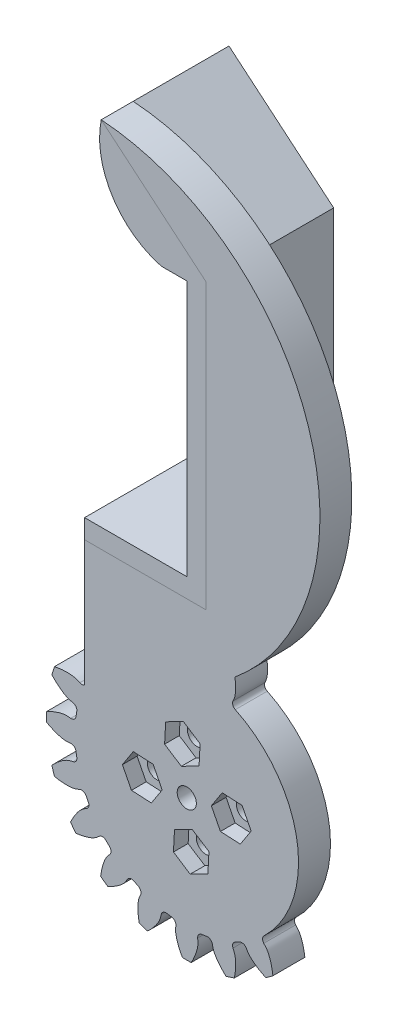
from build123d import *

# Parameters (mm, degrees)
SKETCH_1_R           = 22
LASHENA_DEPTH        = 5
CUT_EXTRUDEA_DEPTH   = 50
WWW_KYTOOL_CN_COUNT  = 20
EXTRUDE_2_DEPTH      = 15
EXTRUDE_2_DEPTH_BACK = 5
EXTRUDE_3_DEPTH      = 5
SKETCH_5_R           = 1.5
CUT_EXTRUDE_2_DEPTH  = 5
CUT_EXTRUDE_4_DEPTH  = 2.3


with BuildPart() as part:
    # 草图1 → LaShenA (new body)
    with BuildSketch(Plane.XY):
        Circle(SKETCH_1_R)
    extrude(amount=LASHENA_DEPTH)

    # SketchA → Cut-ExtrudeA (cut)
    with BuildSketch(Plane.XY.offset(5)):
        with BuildLine():
            ThreePointArc((-2.356349611, 17.340634836), (-2.737603138, 17.28454596), (-3.117529205, 17.220075832))
            ThreePointArc((-3.117529205, 17.220075832), (-3.673572605, 17.334949471), (-3.994833481, 17.803107206))
            add(Edge.make_bspline(
                [(-3.994833481, 17.803107206), (-4.034691495, 17.98253134), (-4.076537521, 18.219177773), (-4.157204778, 18.47396401), (-4.199055268, 18.580395528), (-4.234392911, 18.664311698), (-4.277870663, 18.759955155), (-4.330045748, 18.866984119), (-4.391601943, 18.984969425), (-4.463160419, 19.113474646), (-4.545339737, 19.2520309), (-4.638735544, 19.400145657), (-4.743925671, 19.557300848), (-4.861467358, 19.722954334), (-4.991896938, 19.896540395), (-5.135728792, 20.077470549), (-5.293454567, 20.265134311), (-5.465542346, 20.458900012), (-5.65243587, 20.658115632), (-5.854553762, 20.862109666), (-6.07228887, 21.070192005), (-6.3060073, 21.281654905), (-6.646489341, 21.573220913), (-6.916345556, 21.785433413), (-7.103559199, 21.924886291)],
                knots=[0.125068197, 0.125068197, 0.125068197, 0.125068197, 0.215847125, 0.244833276, 0.257593391, 0.272673526, 0.290073681, 0.309793857, 0.331834054, 0.356194271, 0.382874509, 0.411874767, 0.443195046, 0.476835345, 0.512795666, 0.551076006, 0.591676368, 0.634596749, 0.679837152, 0.727397575, 0.777278019, 0.829478483, 0.883998968, 1, 1, 1, 1], degree=3))
            ThreePointArc((-7.103559199, 21.924886291), (-3.605334877, 22.763188542), (-0.019276198, 23.046926489))
            add(Edge.make_bspline(
                [(-1.702150265, 18.166232554), (-1.719688148, 18.349191849), (-1.753017983, 18.587187115), (-1.755032138, 18.854430779), (-1.748119105, 18.96858568), (-1.740442532, 19.059314632), (-1.728648187, 19.16371233), (-1.712100501, 19.281625912), (-1.690016545, 19.412858516), (-1.661670688, 19.557187029), (-1.626329749, 19.714356663), (-1.583275034, 19.88408306), (-1.531796904, 20.066052064), (-1.471197858, 20.259920271), (-1.400793, 20.465315382), (-1.31991127, 20.681836671), (-1.227896436, 20.90905546), (-1.124108127, 21.146515641), (-1.007922835, 21.393734229), (-0.87873492, 21.650201949), (-0.735957506, 21.915383862), (-0.579023699, 22.188719998), (-0.345304887, 22.571230486), (-0.154233644, 22.856446723), (-0.019276198, 23.046926489)],
                knots=[0.125068197, 0.125068197, 0.125068197, 0.125068197, 0.215847125, 0.244833276, 0.257593391, 0.272673526, 0.290073681, 0.309793857, 0.331834054, 0.356194271, 0.382874509, 0.411874767, 0.443195046, 0.476835345, 0.512795666, 0.551076006, 0.591676368, 0.634596749, 0.679837152, 0.727397575, 0.777278019, 0.829478483, 0.883998968, 1, 1, 1, 1], degree=3))
            ThreePointArc((-1.702150265, 18.166232554), (-1.86301882, 17.621713019), (-2.356349611, 17.340634836))
        make_face()
    cut_extrudea = extrude(amount=-CUT_EXTRUDEA_DEPTH, mode=Mode.SUBTRACT)

    # www.KYTool.cn: Cut-ExtrudeA ×20 about axis
    www_kytool_cn_axis = Axis((0, 0, -88.99), (0, 0, 1))
    for i in range(1, WWW_KYTOOL_CN_COUNT):
        add(cut_extrudea.rotate(www_kytool_cn_axis, i * 360 / WWW_KYTOOL_CN_COUNT), mode=Mode.SUBTRACT)

    # 草图4 → 凸台-拉伸3 (add)
    with BuildSketch(Plane(origin=(0, 0, 0), x_dir=(-1, 0, 0), z_dir=(0, 0, -1))):
        with BuildLine():
            Line((16, 27), (16, 6.979977048))
            Line((16, 6.979977048), (11.899995844, 6.979977048))
            Line((11.899995844, 6.979977048), (11.899995844, 11.882558972))
            ThreePointArc((11.899995844, 11.882558972), (-20.838640796, 49.249376986), (13.392526033, 85.253885523))
            Line((13.392526033, 85.253885523), (-3, 71.498922974))
            Line((-3, 71.498922974), (-3, 27))
            Line((-3, 27), (16, 27))
        make_face()
    extrude(amount=-EXTRUDE_3_DEPTH)

    # 草图5 → 切除-拉伸2 (cut)
    with BuildSketch(Plane(origin=(0, 0, 0), x_dir=(-1, 0, 0), z_dir=(0, 0, -1))):
        with Locations((-6.965660702, 0.692510638)):
            Circle(SKETCH_5_R)
        with Locations((0.692510638, 6.965660702)):
            Circle(SKETCH_5_R)
        with Locations((6.965660702, -0.692510638)):
            Circle(SKETCH_5_R)
        with Locations((-0.692510638, -6.965660702)):
            Circle(SKETCH_5_R)
        Circle(SKETCH_5_R)
        with BuildLine():
            Line((-8.967977297, 20.552307221), (-7.944833745, 15.592614173))
            ThreePointArc((-7.944833745, 15.592614173), (-17.28454596, 2.737603138), (-12.374368671, -12.374368671))
            Line((-12.374368671, -12.374368671), (-16.761996385, -17.415313964))
            Line((-16.761996385, -17.415313964), (-29.980646955, -2.009404666))
            Line((-29.980646955, -2.009404666), (-16.195440918, 18.536343166))
            Line((-16.195440918, 18.536343166), (-8.967977297, 20.552307221))
        make_face()
        Polygon((16, 13.234600946), (16, 9.475893134), (20.716653434, 9.827432459), (20.716653434, 14.843599575), align=None)
    extrude(amount=-CUT_EXTRUDE_2_DEPTH, mode=Mode.SUBTRACT)

    # 草图7 → 切除-拉伸4 (cut)
    with BuildSketch(Plane.XY.offset(5)):
        Polygon((5.26919407, -1.923211244), (8.382708985, -2.084533503), (10.079175618, 0.531188379), (8.662127334, 3.30823252), (5.548612419, 3.469554779), (3.852145787, 0.853832897), align=None)
        Polygon((1.923211244, 5.26919407), (2.084533503, 8.382708985), (-0.531188379, 10.079175618), (-3.30823252, 8.662127334), (-3.469554779, 5.548612419), (-0.853832897, 3.852145787), align=None)
        Polygon((-1.923211244, -5.26919407), (-2.084533503, -8.382708985), (0.531188379, -10.079175618), (3.30823252, -8.662127334), (3.469554779, -5.548612419), (0.853832897, -3.852145787), align=None)
        Polygon((-5.26919407, 1.923211244), (-8.382708985, 2.084533503), (-10.079175618, -0.531188379), (-8.662127334, -3.30823252), (-5.548612419, -3.469554779), (-3.852145787, -0.853832897), align=None)
    extrude(amount=-CUT_EXTRUDE_4_DEPTH, mode=Mode.SUBTRACT)


with BuildPart() as body_2:
    # 草图3 → 凸台-拉伸2 (new body, two sides)
    with BuildSketch(Plane(origin=(0, 0, 0), x_dir=(-1, 0, 0), z_dir=(0, 0, -1))) as extrude_2_sk:
        with BuildLine():
            Line((0, 70.1), (4, 70.1))
            ThreePointArc((4, 70.1), (11.703223048, 75.813199609), (13.392526033, 85.253885523))
            Line((13.392526033, 85.253885523), (-3, 71.498922974))
            Line((-3, 71.498922974), (-3, 27))
            Line((-3, 27), (13, 27))
            Line((13, 27), (16, 27))
            Line((16, 27), (16, 30))
            Line((16, 30), (0, 30))
            Line((0, 30), (0, 70.1))
        make_face()
    extrude(amount=EXTRUDE_2_DEPTH)
    extrude(extrude_2_sk.sketch, amount=-EXTRUDE_2_DEPTH_BACK)


solid = Compound([part.part, body_2.part])
